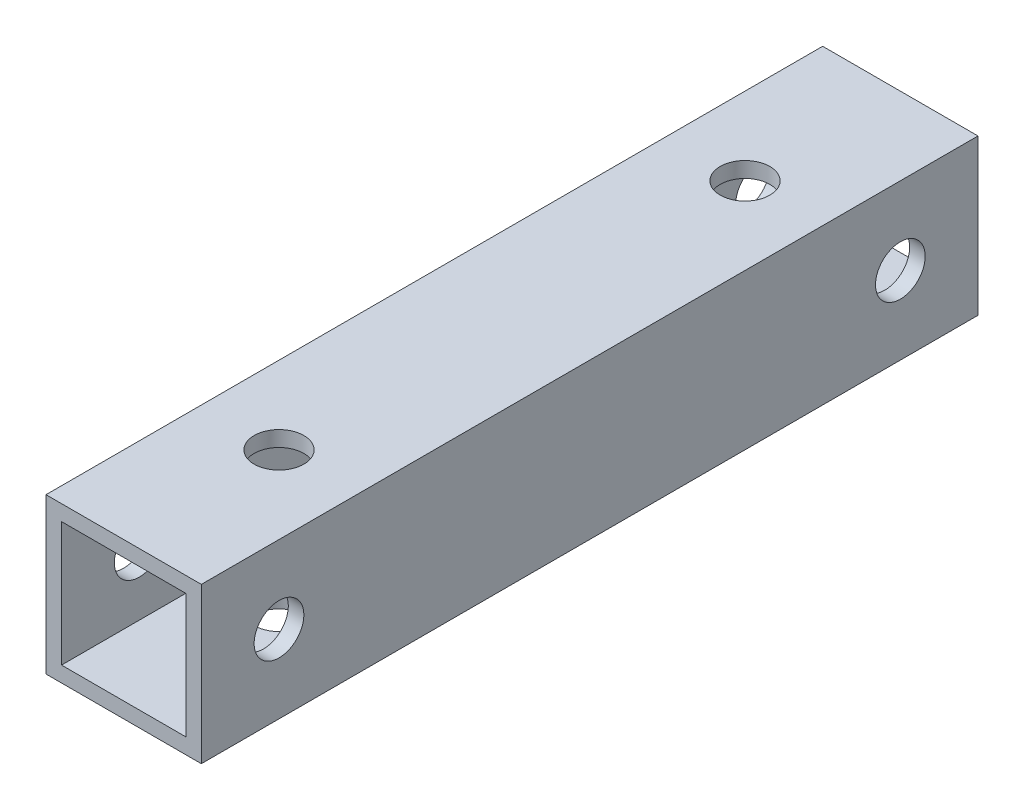
from build123d import *

# Parameters (mm, degrees)
SKETCH_1_W          = 10
SKETCH_1_H          = 10
SKETCH_1_W_2        = 8
SKETCH_1_H_2        = 8
EXTRUDE_1_DEPTH     = 25
SKETCH_3_R          = 1.6
CUT_EXTRUDE_1_DEPTH = 11
SKETCH_4_R          = 1.6
CUT_EXTRUDE_2_DEPTH = 11


with BuildPart() as part:
    # ｽｹｯﾁ1 → ﾎﾞｽ - 押し出し1 (new body, symmetric)
    with BuildSketch(Plane.XY):
        Rectangle(SKETCH_1_W, SKETCH_1_H)
        Rectangle(SKETCH_1_W_2, SKETCH_1_H_2, mode=Mode.SUBTRACT)
    extrude(amount=EXTRUDE_1_DEPTH, both=True)

    # ｽｹｯﾁ3 → ｶｯﾄ - 押し出し1 (cut, through all)
    with BuildSketch(Plane(origin=(5, 0, 0), x_dir=(0, 0, -1), z_dir=(1, 0, 0))):
        with Locations((-20, 0)):
            Circle(SKETCH_3_R)
        with Locations((20, 0)):
            Circle(SKETCH_3_R)
    extrude(amount=-CUT_EXTRUDE_1_DEPTH, mode=Mode.SUBTRACT)

    # ｽｹｯﾁ4 → ｶｯﾄ - 押し出し2 (cut, through all)
    with BuildSketch(Plane(origin=(0, 5, 0), x_dir=(1, 0, 0), z_dir=(0, 1, 0))):
        with Locations((0, -15)):
            Circle(SKETCH_4_R)
        with Locations((0, 15)):
            Circle(SKETCH_4_R)
    extrude(amount=-CUT_EXTRUDE_2_DEPTH, mode=Mode.SUBTRACT)


solid = part.part
